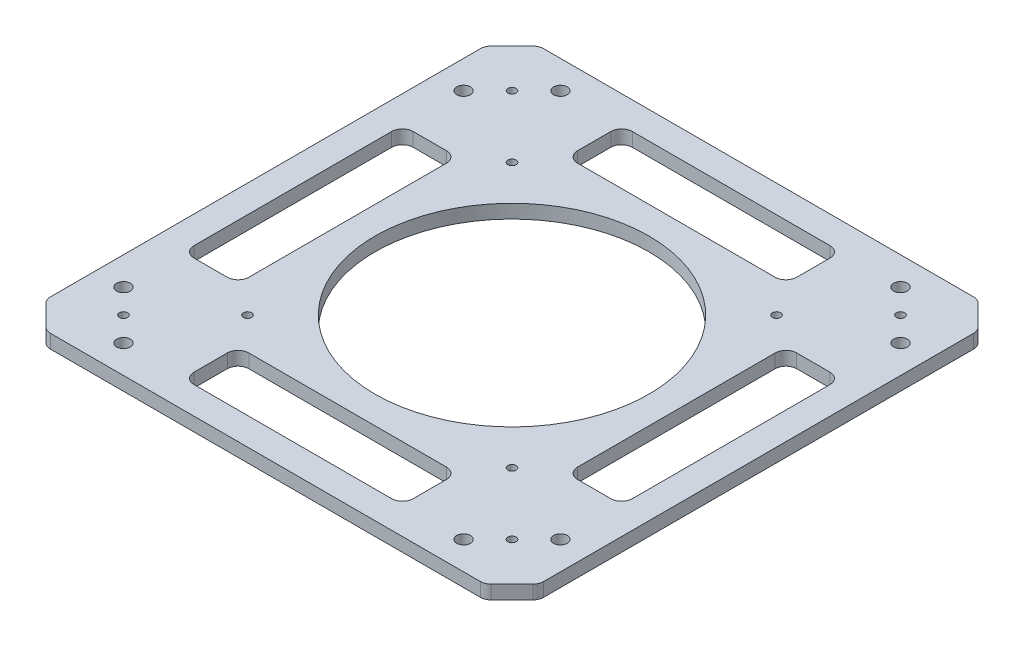
from build123d import *

# Parameters (mm, degrees)
BOSS_EXTRUDE1_DEPTH     = 12.7
SKETCH2_R               = 6.35
SKETCH2_R_2             = 127
SKETCH2_R_3             = 3.81
CUT_EXTRUDE1_DEPTH      = 1
CUT_EXTRUDE1_DEPTH_BACK = 13.7
SKETCH3_W               = 50.8
SKETCH3_H               = 203.2
SKETCH3_W_2             = 203.2
SKETCH3_H_2             = 50.8
CUT_EXTRUDE2_DEPTH      = 1
CUT_EXTRUDE2_DEPTH_BACK = 13.7
FILLET1_R               = 10
FILLET2_R               = 10
SCALE1_SCALE            = 0.5


with BuildPart() as part:
    # Sketch1 → Boss-Extrude1 (new body)
    with BuildSketch(Plane(origin=(0, 0, 0), x_dir=(1, 0, 0), z_dir=(0, 1, 0))):
        Polygon((-203.454, 228.598717139), (203.454, 228.598717139), (228.598717139, 203.454), (228.598717139, -203.454), (203.454, -228.598717139), (-203.454, -228.598717139), (-228.598717139, -203.454), (-228.598717139, 203.454), align=None)
    extrude(amount=BOSS_EXTRUDE1_DEPTH)

    # Sketch2 → Cut-Extrude1 (cut, two sides)
    with BuildSketch(Plane(origin=(0, 12.7, 0), x_dir=(1, 0, 0), z_dir=(0, 1, 0))) as cut_extrude1_sk:
        with Locations((202.555974388, 157.654693783)):
            Circle(SKETCH2_R)
        with Locations((157.654693783, 202.555974388)):
            Circle(SKETCH2_R)
        with Locations((-157.654693783, 202.555974388)):
            Circle(SKETCH2_R)
        with Locations((-202.555974388, 157.654693783)):
            Circle(SKETCH2_R)
        with Locations((-157.654693783, -202.555974388)):
            Circle(SKETCH2_R)
        with Locations((-202.555974388, -157.654693783)):
            Circle(SKETCH2_R)
        with Locations((157.654693783, -202.555974388)):
            Circle(SKETCH2_R)
        with Locations((202.555974388, -157.654693783)):
            Circle(SKETCH2_R)
        Circle(SKETCH2_R_2)
        with Locations((180.105334085, 180.105334085)):
            Circle(SKETCH2_R_3)
        with Locations((122.63169491, 122.63169491)):
            Circle(SKETCH2_R_3)
        with Locations((-180.105334085, 180.105334085)):
            Circle(SKETCH2_R_3)
        with Locations((-122.63169491, 122.63169491)):
            Circle(SKETCH2_R_3)
        with Locations((180.105334085, -180.105334085)):
            Circle(SKETCH2_R_3)
        with Locations((122.63169491, -122.63169491)):
            Circle(SKETCH2_R_3)
        with Locations((-122.63169491, -122.63169491)):
            Circle(SKETCH2_R_3)
        with Locations((-180.105334085, -180.105334085)):
            Circle(SKETCH2_R_3)
    extrude(amount=CUT_EXTRUDE1_DEPTH, mode=Mode.SUBTRACT)
    extrude(cut_extrude1_sk.sketch, amount=-CUT_EXTRUDE1_DEPTH_BACK, mode=Mode.SUBTRACT)

    # Sketch3 → Cut-Extrude2 (cut, two sides)
    with BuildSketch(Plane(origin=(0, 12.7, 0), x_dir=(1, 0, 0), z_dir=(0, 1, 0))) as cut_extrude2_sk:
        with Locations((177.798717139, 0)):
            Rectangle(SKETCH3_W, SKETCH3_H)
        with Locations((0, -177.798717139)):
            Rectangle(SKETCH3_W_2, SKETCH3_H_2)
        with Locations((-177.798717139, 0)):
            Rectangle(SKETCH3_W, SKETCH3_H)
        with Locations((0, 177.798717139)):
            Rectangle(SKETCH3_W_2, SKETCH3_H_2)
    extrude(amount=CUT_EXTRUDE2_DEPTH, mode=Mode.SUBTRACT)
    extrude(cut_extrude2_sk.sketch, amount=-CUT_EXTRUDE2_DEPTH_BACK, mode=Mode.SUBTRACT)

    # Fillet1
    fillet1_edges = [part.edges().sort_by_distance(p)[0] for p in [
        (228.598717139, 6.35, -203.454),
        (228.598717139, 6.35, 203.454),
        (203.454, 6.35, 228.598717139),
        (-203.454, 6.35, 228.598717139),
        (-228.598717139, 6.35, 203.454),
        (-228.598717139, 6.35, -203.454),
        (-203.454, 6.35, -228.598717139),
        (203.454, 6.35, -228.598717139),
    ]]
    fillet(fillet1_edges, radius=FILLET1_R)

    # Fillet2
    fillet2_edges = [part.edges().sort_by_distance(p)[0] for p in [
        (203.198717139, 6.35, -101.6),
        (203.198717139, 6.35, 101.6),
        (152.398717139, 6.35, 101.6),
        (152.398717139, 6.35, -101.6),
        (101.6, 6.35, 203.198717139),
        (-101.6, 6.35, 203.198717139),
        (-101.6, 6.35, 152.398717139),
        (101.6, 6.35, 152.398717139),
        (-203.198717139, 6.35, 101.6),
        (-203.198717139, 6.35, -101.6),
        (-152.398717139, 6.35, -101.6),
        (-152.398717139, 6.35, 101.6),
        (-101.6, 6.35, -203.198717139),
        (101.6, 6.35, -203.198717139),
        (101.6, 6.35, -152.398717139),
        (-101.6, 6.35, -152.398717139),
    ]]
    fillet(fillet2_edges, radius=FILLET2_R)


with BuildPart() as part_1:
    # Scale1: scaled about (0, 6.35, 0)
    add(part.part.scale(SCALE1_SCALE).moved(Location((0, 3.175, 0))))


solid = part_1.part
